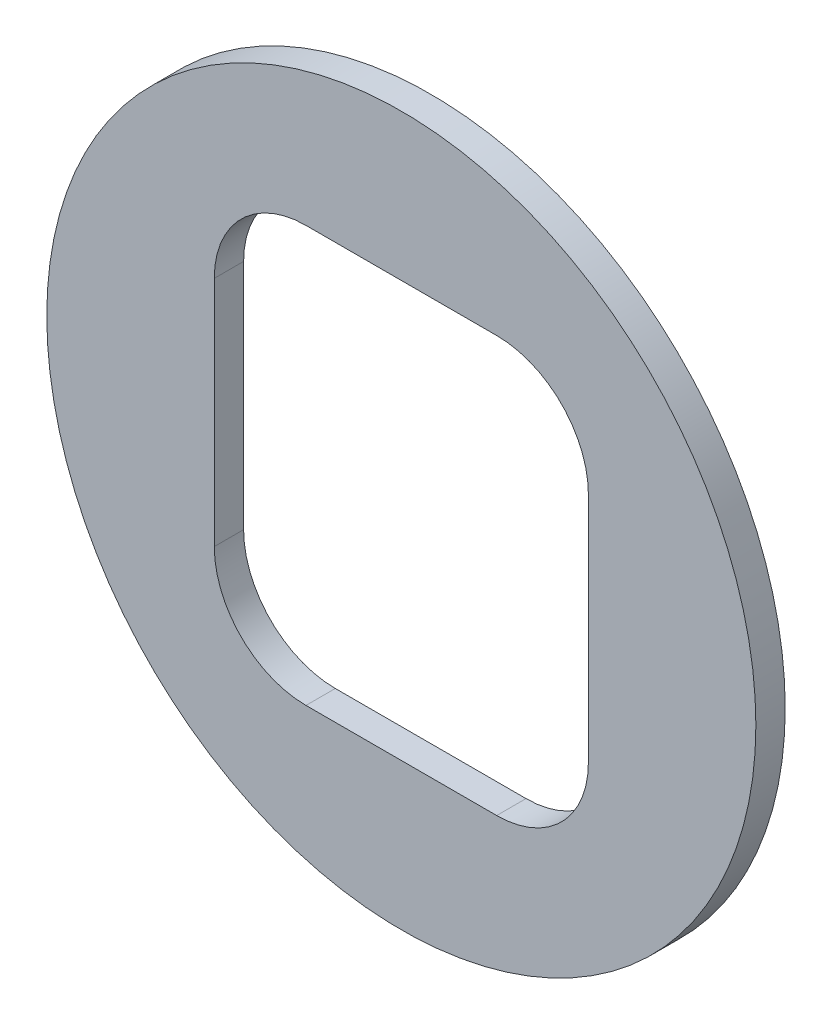
from build123d import *

# Parameters (mm, degrees)
SKETCH1_R      = 18.415
SKETCH1_W      = 19.431
SKETCH1_H      = 21.59
EXTRUDE1_DEPTH = 1.524
FILLET1_R      = 4.7625


with BuildPart() as part:
    # Sketch1 → Extrude1 (new body)
    with BuildSketch(Plane.XY):
        Circle(SKETCH1_R)
        Rectangle(SKETCH1_W, SKETCH1_H, mode=Mode.SUBTRACT)
    extrude(amount=EXTRUDE1_DEPTH)

    # Fillet1
    fillet1_edges = [part.edges().sort_by_distance(p)[0] for p in [
        (-9.7155, 10.795, 0.762),
        (-9.7155, -10.795, 0.762),
        (9.7155, -10.795, 0.762),
        (9.7155, 10.795, 0.762),
    ]]
    fillet(fillet1_edges, radius=FILLET1_R)


solid = part.part
